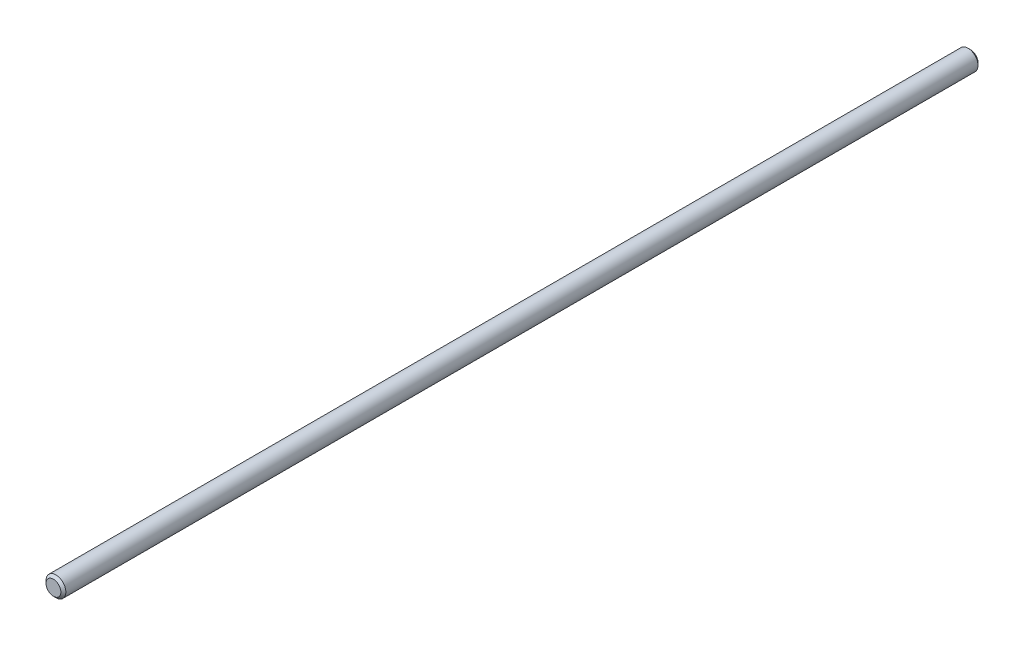
from build123d import *

# Parameters (mm, degrees)
SCHIZZO1_R                   = 4
ESTRUSIONE_ESTRUSIONE1_DEPTH = 370
SMUSSO1_SIZE                 = 1


with BuildPart() as part:
    # Schizzo1 → Estrusione-Estrusione1 (new body)
    with BuildSketch(Plane.XY):
        Circle(SCHIZZO1_R)
    extrude(amount=ESTRUSIONE_ESTRUSIONE1_DEPTH)

    # Smusso1
    smusso1_edges = [part.edges().sort_by_distance(p)[0] for p in [
        (-4, 0, 0),
        (-4, 0, 370),
    ]]
    chamfer(smusso1_edges, length=SMUSSO1_SIZE)


solid = part.part
